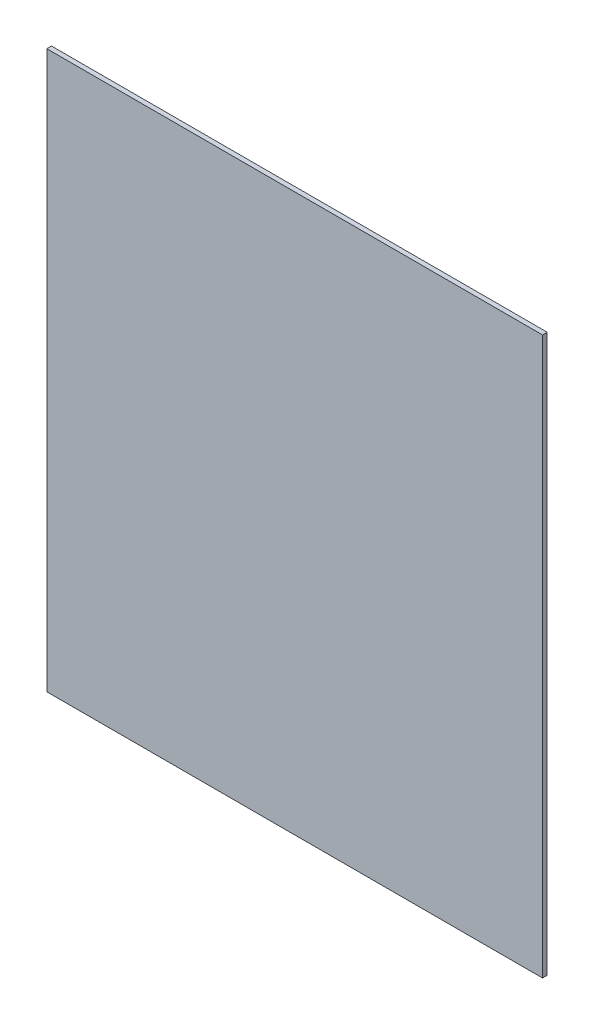
from build123d import *

# Parameters (mm, degrees)
SKETCH1_W           = 128.5875
SKETCH1_H           = 144.4625
BOSS_EXTRUDE1_DEPTH = 1.21412


with BuildPart() as part:
    # Sketch1 → Boss-Extrude1 (new body)
    with BuildSketch(Plane.XY):
        Rectangle(SKETCH1_W, SKETCH1_H)
    extrude(amount=BOSS_EXTRUDE1_DEPTH)


solid = part.part
